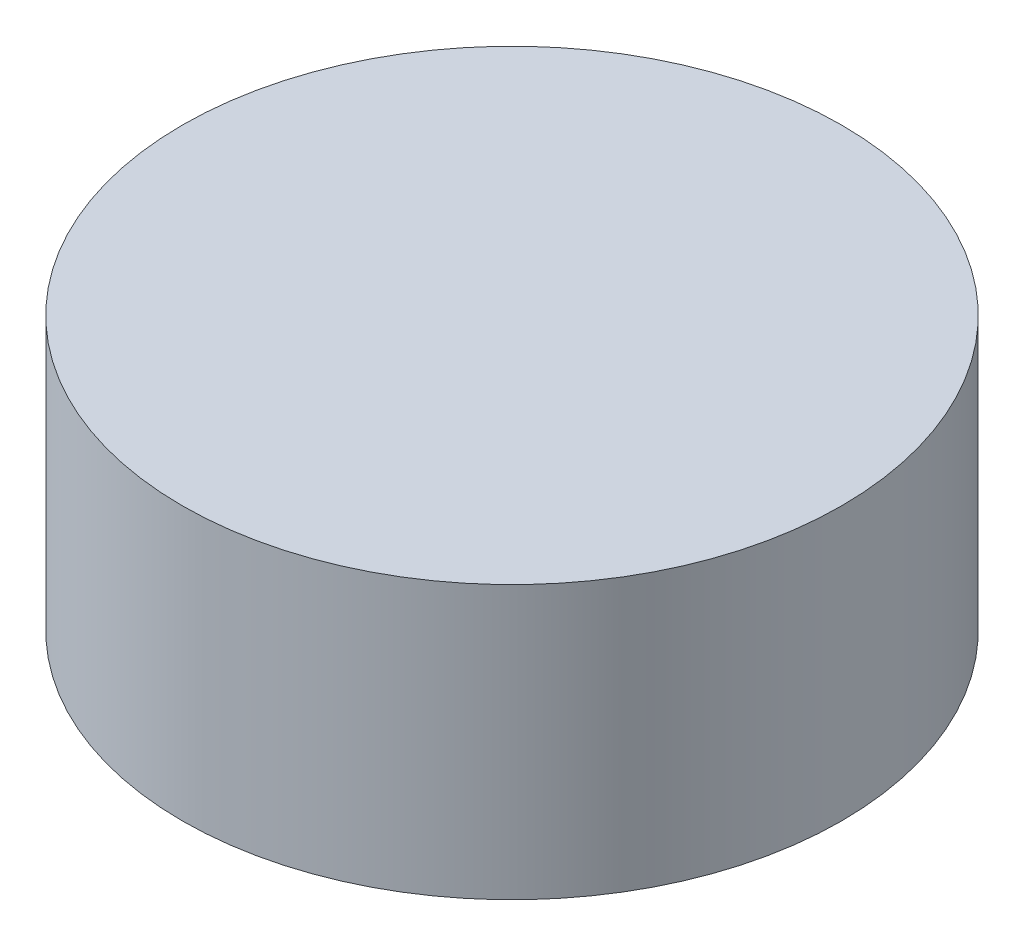
from build123d import *

# Parameters (mm, degrees)
BOSS_EXTRUDE1_DEPTH = 10
SKETCH4_W           = 152.759028905
SKETCH4_H           = 70.023532291
SKETCH4_R           = 12.08003571
CUT_EXTRUDE1_DEPTH  = 11.0000001


with BuildPart() as part:
    # Sketch2 → Boss-Extrude1 (new body)
    with BuildSketch(Plane(origin=(0, 0, 0), x_dir=(1, 0, 0), z_dir=(0, 1, 0))):
        with BuildLine():
            add(Edge.make_bspline(
                [(-109.1, -5.1), (-109.424609826, 10.441471911), (-73.787625733, 25.22270358), (-43.020276746, 23.937309848), (-34.219540496, 17.85083091), (-19.745412821, 17.556799812), (-9.831464388, 20.08956268), (7.173597662, 19.935183257), (19.6, 14.289300505), (19.6, 0)],
                knots=[0, 0, 0, 0, 0.230584101, 0.286176341, 0.525950611, 0.574149071, 0.719962477, 0.764370237, 1, 1, 1, 1], degree=3))
            add(Edge.make_bspline(
                [(19.6, 0), (19.6, -12.798208112), (9.628339195, -19.558649887), (-8.537408911, -19.135204318), (-19.796385689, -17.357223298), (-41.21861702, -17.372886462), (-58.113965099, -28.979482333), (-85.155395015, -28.327654779), (-109.1, -26.64326042), (-109.1, -5.1)],
                knots=[0, 0, 0, 0, 0.174620331, 0.213184502, 0.3664798, 0.418282358, 0.679407529, 0.740843358, 1, 1, 1, 1], degree=3))
        make_face()
    extrude(amount=BOSS_EXTRUDE1_DEPTH)

    # Sketch4 → Cut-Extrude1 (cut, through all)
    with BuildSketch(Plane(origin=(0, 10, 0), x_dir=(1, 0, 0), z_dir=(0, 1, 0))):
        with Locations((-43.537567524, 1.623567221)):
            Rectangle(SKETCH4_W, SKETCH4_H)
        with Locations((-46.446237326, 0)):
            Circle(SKETCH4_R, mode=Mode.SUBTRACT)
    extrude(amount=-CUT_EXTRUDE1_DEPTH, mode=Mode.SUBTRACT)


solid = part.part
